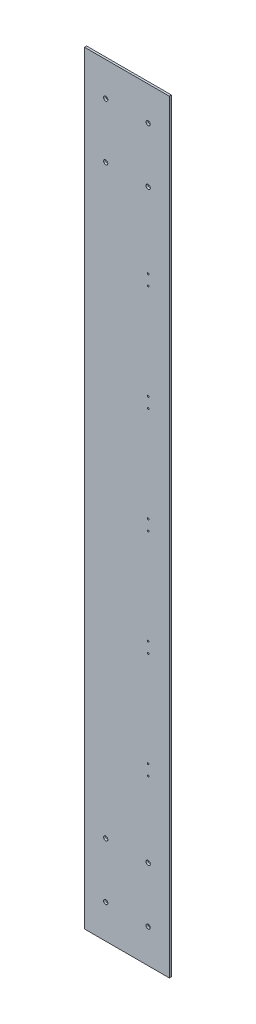
from build123d import *

# Parameters (mm, degrees)
SKETCH2_W           = 200
SKETCH2_H           = 1800
BOSS_EXTRUDE1_DEPTH = 5
SKETCH3_R           = 5
SKETCH3_R_2         = 2
CUT_EXTRUDE1_DEPTH  = 5


with BuildPart() as part:
    # Sketch2 → Boss-Extrude1 (new body)
    with BuildSketch(Plane.XY):
        Rectangle(SKETCH2_W, SKETCH2_H)
    extrude(amount=BOSS_EXTRUDE1_DEPTH)

    # Sketch3 → Cut-Extrude1 (cut)
    with BuildSketch(Plane.XY.offset(5)):
        with Locations((-50, -690)):
            Circle(SKETCH3_R)
        with Locations((50, -690)):
            Circle(SKETCH3_R)
        with Locations((-50, -820)):
            Circle(SKETCH3_R)
        with Locations((50, -820)):
            Circle(SKETCH3_R)
        with Locations((50, 820)):
            Circle(SKETCH3_R)
        with Locations((-50, 820)):
            Circle(SKETCH3_R)
        with Locations((50, 690)):
            Circle(SKETCH3_R)
        with Locations((-50, 690)):
            Circle(SKETCH3_R)
        with Locations((50, 512.5)):
            Circle(SKETCH3_R_2)
        with Locations((50, 487.5)):
            Circle(SKETCH3_R_2)
        with Locations((50, 262.5)):
            Circle(SKETCH3_R_2)
        with Locations((50, 237.5)):
            Circle(SKETCH3_R_2)
        with Locations((50, 12.5)):
            Circle(SKETCH3_R_2)
        with Locations((50, -12.5)):
            Circle(SKETCH3_R_2)
        with Locations((50, -237.5)):
            Circle(SKETCH3_R_2)
        with Locations((50, -262.5)):
            Circle(SKETCH3_R_2)
        with Locations((50, -487.5)):
            Circle(SKETCH3_R_2)
        with Locations((50, -512.5)):
            Circle(SKETCH3_R_2)
    extrude(amount=-CUT_EXTRUDE1_DEPTH, mode=Mode.SUBTRACT)


solid = part.part
